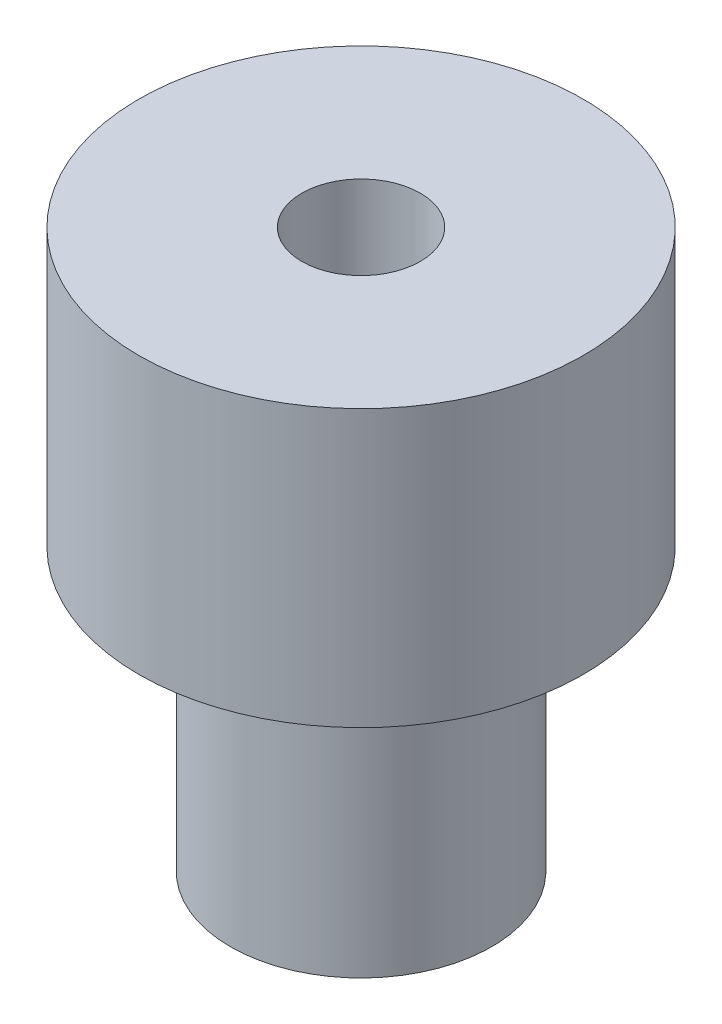
from build123d import *

# Parameters (mm, degrees)
SKETCH1_R           = 5.95
SKETCH1_R_2         = 1.586
BOSS_EXTRUDE1_DEPTH = 7.4
SKETCH2_R           = 3.5
SKETCH2_R_2         = 1.586
BOSS_EXTRUDE2_DEPTH = 7.54
SKETCH3_R           = 1.25
CUT_EXTRUDE1_DEPTH  = 10


with BuildPart() as part:
    # Sketch1 → Boss-Extrude1 (new body)
    with BuildSketch(Plane(origin=(0, 0, 0), x_dir=(1, 0, 0), z_dir=(0, 1, 0))):
        Circle(SKETCH1_R)
        Circle(SKETCH1_R_2, mode=Mode.SUBTRACT)
    extrude(amount=BOSS_EXTRUDE1_DEPTH)

    # Sketch2 → Boss-Extrude2 (add)
    with BuildSketch(Plane.XZ):
        Circle(SKETCH2_R)
        Circle(SKETCH2_R_2, mode=Mode.SUBTRACT)
    extrude(amount=BOSS_EXTRUDE2_DEPTH)

    # Sketch3 → Cut-Extrude1 (cut)
    with BuildSketch(Plane(origin=(0, 0, 0), x_dir=(0, 0, -1), z_dir=(1, 0, 0))):
        with Locations((0, -3.77)):
            Circle(SKETCH3_R)
    extrude(amount=-CUT_EXTRUDE1_DEPTH, mode=Mode.SUBTRACT)


solid = part.part
